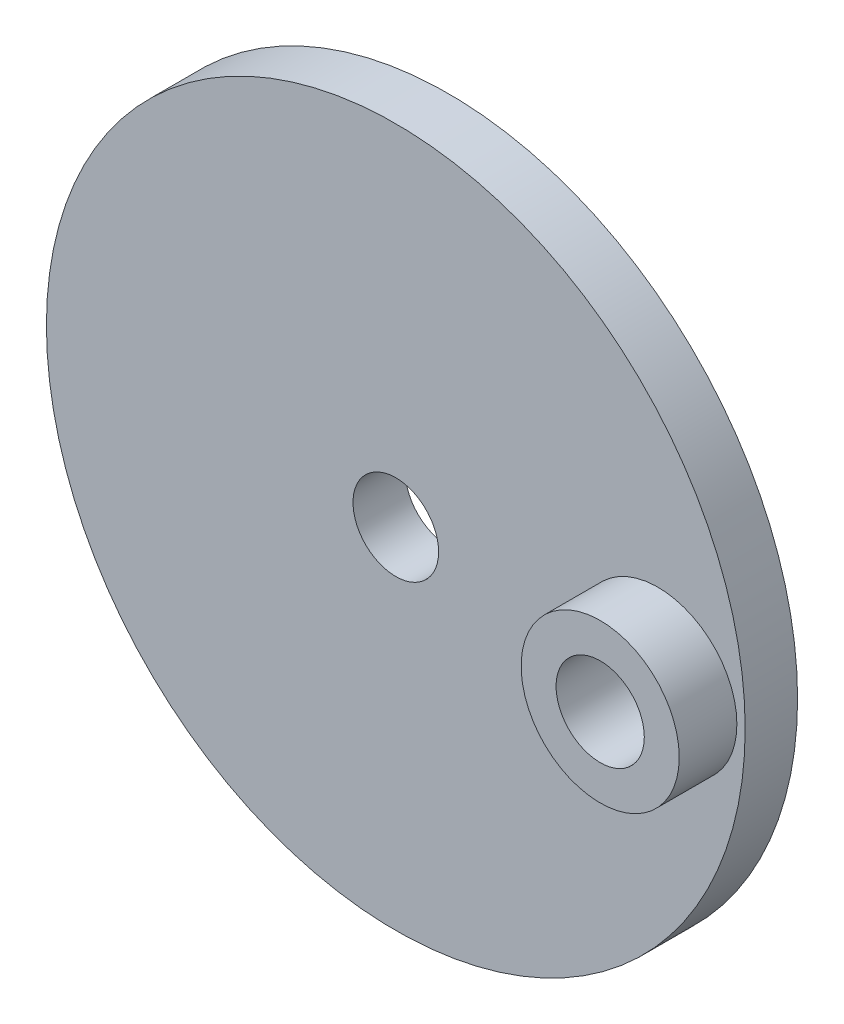
from build123d import *

# Parameters (mm, degrees)
SKETCH1_R               = 20
BOSS_EXTRUDE1_DEPTH     = 3
CUT_EXTRUDE3_START      = 3
SKETCH2_R               = 2.525
CUT_EXTRUDE3_DEPTH      = 4
CUT_EXTRUDE3_DEPTH_BACK = 4
BOSS_EXTRUDE2_START     = 3
SKETCH3_R               = 4.525
SKETCH3_R_2             = 2.525
BOSS_EXTRUDE2_DEPTH     = 3.3
SKETCH4_R               = 2.45
CUT_EXTRUDE4_DEPTH      = 7.3


with BuildPart() as part:
    # Sketch1 → Boss-Extrude1 (new body)
    with BuildSketch(Plane.XY):
        Circle(SKETCH1_R)
    extrude(amount=BOSS_EXTRUDE1_DEPTH)

    # Sketch2 → Cut-Extrude3 (cut, two sides)
    with BuildSketch(Plane.XY.offset(CUT_EXTRUDE3_START)) as cut_extrude3_sk:
        with Locations((15, 0)):
            Circle(SKETCH2_R)
    extrude(amount=CUT_EXTRUDE3_DEPTH, mode=Mode.SUBTRACT)
    extrude(cut_extrude3_sk.sketch, amount=-CUT_EXTRUDE3_DEPTH_BACK, mode=Mode.SUBTRACT)

    # Sketch3 → Boss-Extrude2 (add)
    with BuildSketch(Plane.XY.offset(BOSS_EXTRUDE2_START)):
        with Locations((15, 0)):
            Circle(SKETCH3_R)
        with Locations((15, 0)):
            Circle(SKETCH3_R_2, mode=Mode.SUBTRACT)
    extrude(amount=BOSS_EXTRUDE2_DEPTH)

    # Sketch4 → Cut-Extrude4 (cut, through all)
    with BuildSketch(Plane.XY):
        Circle(SKETCH4_R)
    extrude(amount=CUT_EXTRUDE4_DEPTH, mode=Mode.SUBTRACT)


solid = part.part
